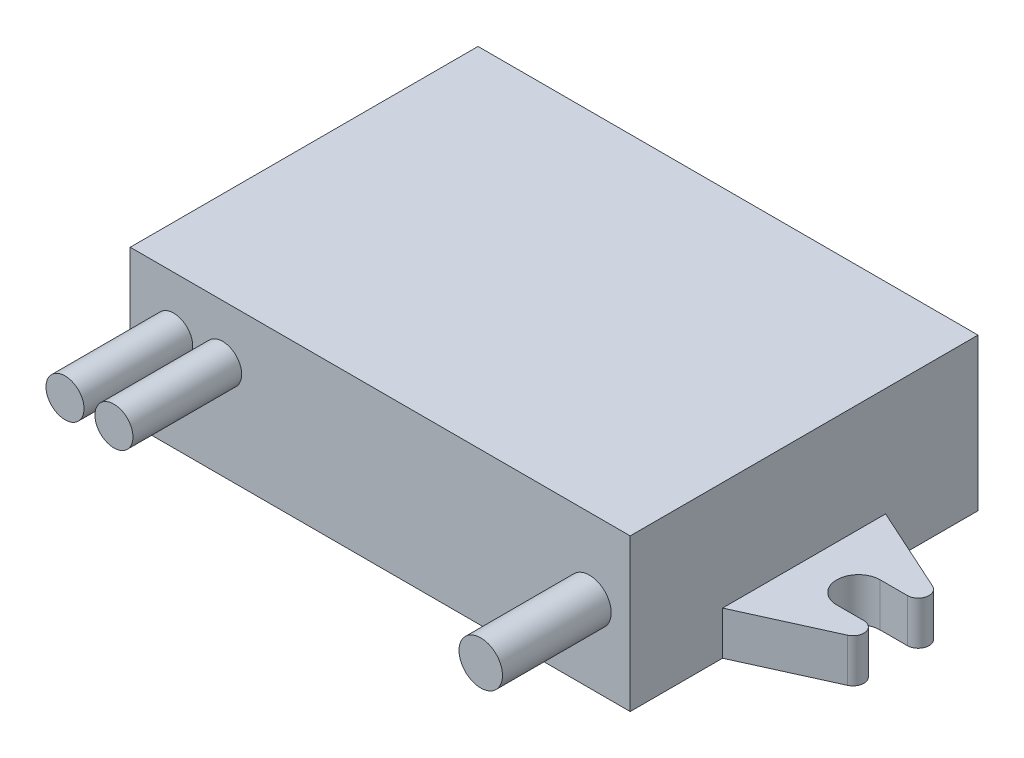
from build123d import *

# Parameters (mm, degrees)
SKETCH1_W            = 46
SKETCH1_H            = 32
BOSS_EXTRUDE1_DEPTH  = 14
BOSS_EXTRUDE2_DEPTH  = 4
MIRROR2_COPY_1_DEPTH = 4
SKETCH3_R            = 1.75
SKETCH3_R_2          = 2
BOSS_EXTRUDE3_DEPTH  = 10


with BuildPart() as part:
    # Sketch1 → Boss-Extrude1 (new body)
    with BuildSketch(Plane(origin=(0, 0, 0), x_dir=(1, 0, 0), z_dir=(0, 1, 0))):
        Rectangle(SKETCH1_W, SKETCH1_H)
    extrude(amount=BOSS_EXTRUDE1_DEPTH)

    # Sketch2 → Boss-Extrude2 (add)
    with BuildSketch(Plane.XZ):
        with BuildLine():
            Line((-28, 2), (-30.5, 2))
            ThreePointArc((-30.5, 2), (-31.477418408, 2.788686832), (-30.913082761, 3.91069349))
            Line((-30.913082761, 3.91069349), (-23, 7.5))
            Line((-23, 7.5), (-23, 0))
            Line((-23, 0), (-26, 0))
            ThreePointArc((-26, 0), (-26.585786438, 1.414213562), (-28, 2))
        make_face()
    boss_extrude2 = extrude(amount=-BOSS_EXTRUDE2_DEPTH)

    # Mirror1: Boss-Extrude2 across plane
    add(boss_extrude2.mirror(Plane.XY))

    # Mirror2: Boss-Extrude2 across plane
    add(boss_extrude2.mirror(Plane(origin=(0, 0, 0), x_dir=(0, 0, 1), z_dir=(1, 0, 0))))

    # Mirror2 copy 1 sketch → Mirror2 copy 1 (add)
    with BuildSketch(Plane(origin=(0, 0, 0), x_dir=(-1, 0, 0), z_dir=(0, -1, 0))):
        with BuildLine():
            Line((-28, 2), (-30.5, 2))
            ThreePointArc((-30.5, 2), (-31.477418408, 2.788686832), (-30.913082761, 3.91069349))
            Line((-30.913082761, 3.91069349), (-23, 7.5))
            Line((-23, 7.5), (-23, 0))
            Line((-23, 0), (-26, 0))
            ThreePointArc((-26, 0), (-26.585786438, 1.414213562), (-28, 2))
        make_face()
    extrude(amount=-MIRROR2_COPY_1_DEPTH)

    # Sketch3 → Boss-Extrude3 (add)
    with BuildSketch(Plane.XY.offset(16)):
        with Locations((-19, 9)):
            Circle(SKETCH3_R)
        with Locations((-14.5, 9)):
            Circle(SKETCH3_R)
        with Locations((19.25, 7)):
            Circle(SKETCH3_R_2)
    extrude(amount=BOSS_EXTRUDE3_DEPTH)


solid = part.part
